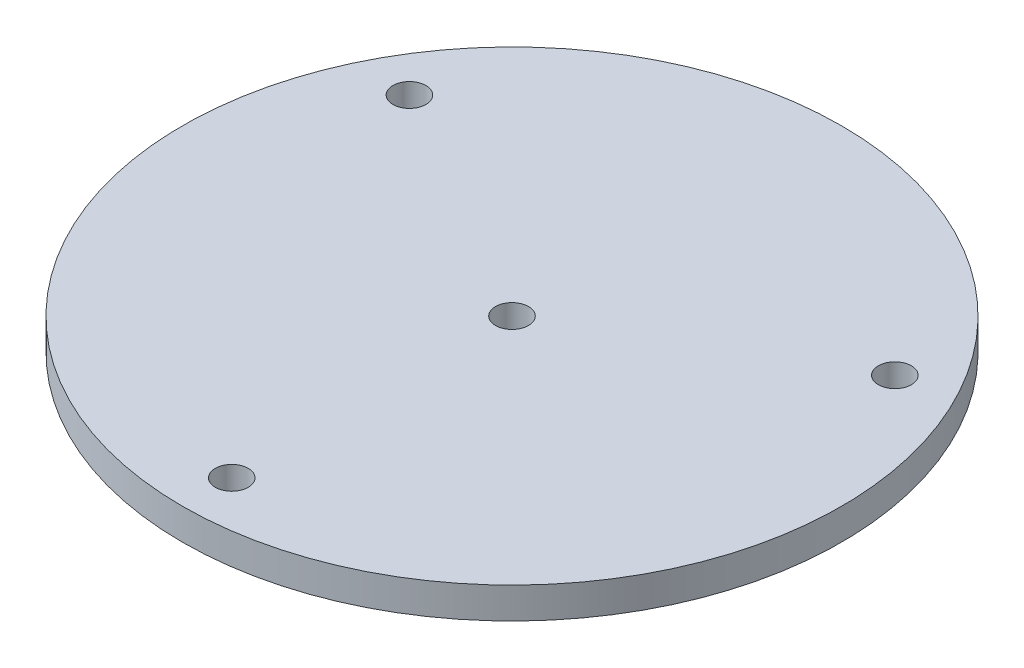
from build123d import *

# Parameters (mm, degrees)
SKETCH1_R           = 63.5
SKETCH1_R_2         = 3.175
BOSS_EXTRUDE1_DEPTH = 6


with BuildPart() as part:
    # Sketch1 → Boss-Extrude1 (new body)
    with BuildSketch(Plane(origin=(0, 0, 0), x_dir=(1, 0, 0), z_dir=(0, 1, 0))):
        Circle(SKETCH1_R)
        Circle(SKETCH1_R_2, mode=Mode.SUBTRACT)
        with Locations((0, -54.0004)):
            Circle(SKETCH1_R_2, mode=Mode.SUBTRACT)
        with Locations((-46.765718215, 27.0002)):
            Circle(SKETCH1_R_2, mode=Mode.SUBTRACT)
        with Locations((46.765718215, 27.0002)):
            Circle(SKETCH1_R_2, mode=Mode.SUBTRACT)
    extrude(amount=BOSS_EXTRUDE1_DEPTH)


solid = part.part
